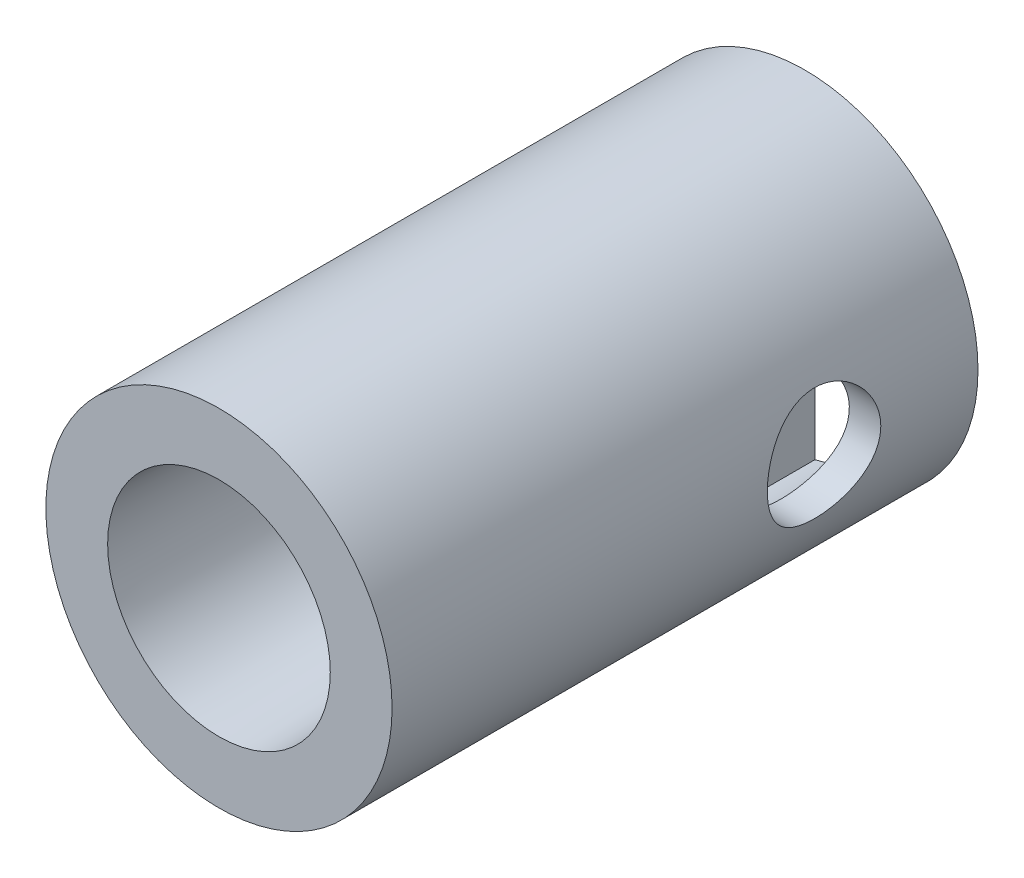
from build123d import *

# Parameters (mm, degrees)
SKETCH1_R                = 4.1275
BOSS_EXTRUDE1_DEPTH      = 6.35
BOSS_EXTRUDE1_DEPTH_BACK = 7.62
CUT_EXTRUDE1_DEPTH       = 7.874
F_2_CLEARANCE_HOLE1_D    = 2.7051
CHAMFER1_SIZE            = 0.508


with BuildPart() as part:
    # Sketch1 → Boss-Extrude1 (new body, two sides)
    with BuildSketch(Plane.XY) as boss_extrude1_sk:
        Circle(SKETCH1_R)
    extrude(amount=BOSS_EXTRUDE1_DEPTH)
    extrude(boss_extrude1_sk.sketch, amount=-BOSS_EXTRUDE1_DEPTH_BACK)

    # Sketch2 → Cut-Extrude1 (cut)
    with BuildSketch(Plane(origin=(0, 0, -7.62), x_dir=(-1, 0, 0), z_dir=(0, 0, -1))):
        with BuildLine():
            Line((-0.746, -3.293929837), (-0.746, 3.293929837))
            ThreePointArc((-0.746, 3.293929837), (-3.377349518, 0), (-0.746, -3.293929837))
        make_face()
        with BuildLine():
            Line((0.746, -3.293929837), (0.746, 3.293929837))
            ThreePointArc((0.746, 3.293929837), (3.377349518, 0), (0.746, -3.293929837))
        make_face()
    extrude(amount=-CUT_EXTRUDE1_DEPTH, mode=Mode.SUBTRACT)

    # #2 Clearance Hole1 (through all)
    with Locations(Plane.ZY.offset(4.1275)):
        with Locations((-3.95, 0)):
            Hole(F_2_CLEARANCE_HOLE1_D / 2)

    # Sketch5 → Hole1 (revolve, cut)
    with BuildSketch(Plane(origin=(0, 0, 6.35), x_dir=(0, -1, 0), z_dir=(1, 0, 0))):
        Polygon((0, 0), (0, 3.81), (2.5273, 3.81), (2.6543, 0), align=None)
    revolve(axis=Axis((0, 0, -103.65), (0, 0, 1)), mode=Mode.SUBTRACT)

    # Chamfer1
    chamfer1_edges = [part.edges().sort_by_distance(p)[0] for p in [
        (3.377349518, 0, -7.62),
        (0.746, 0, -7.62),
        (-3.377349518, 0, -7.62),
        (-0.746, 0, -7.62),
    ]]
    chamfer(chamfer1_edges, length=CHAMFER1_SIZE)


solid = part.part
